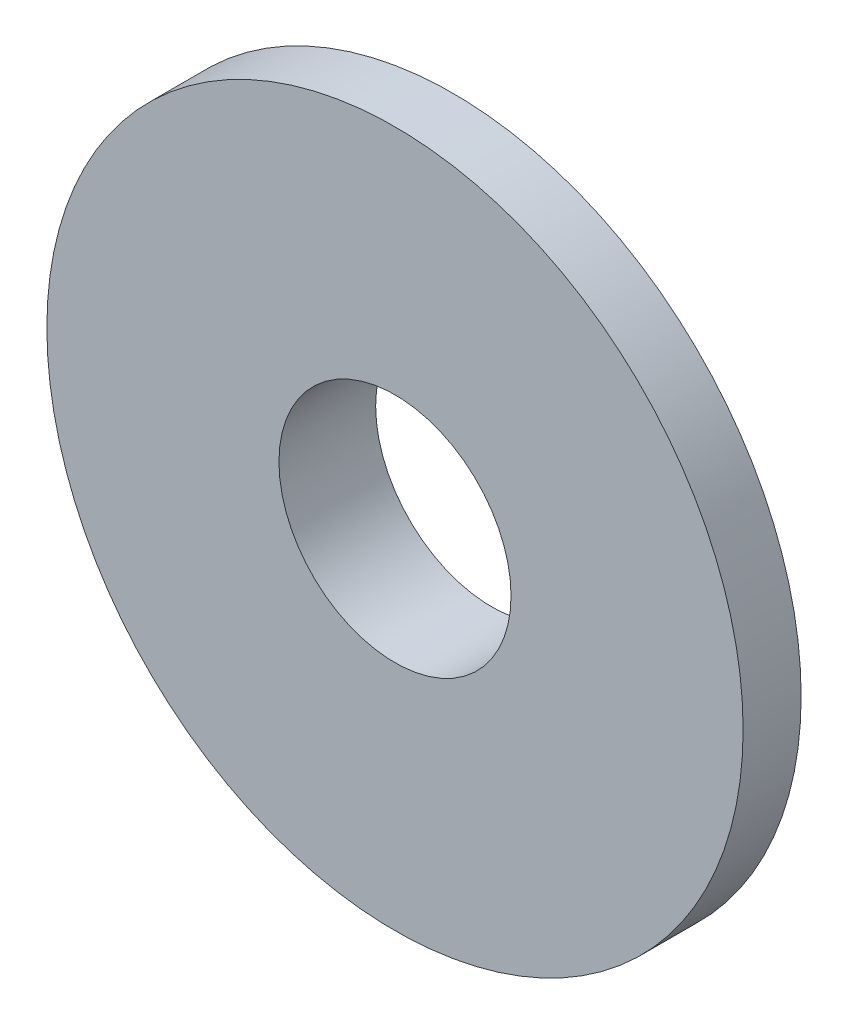
from build123d import *


with BuildPart() as part:
    # Sketch1 → Revolve1 (revolve)
    with BuildSketch(Plane.XZ):
        Polygon((5.500000001, 0), (9, 1), (9, 2.5), (3, 2.5), (3, 0), align=None)
    revolve(axis=Axis((0, 0, 2.5), (0, 0, -1)))


solid = part.part
